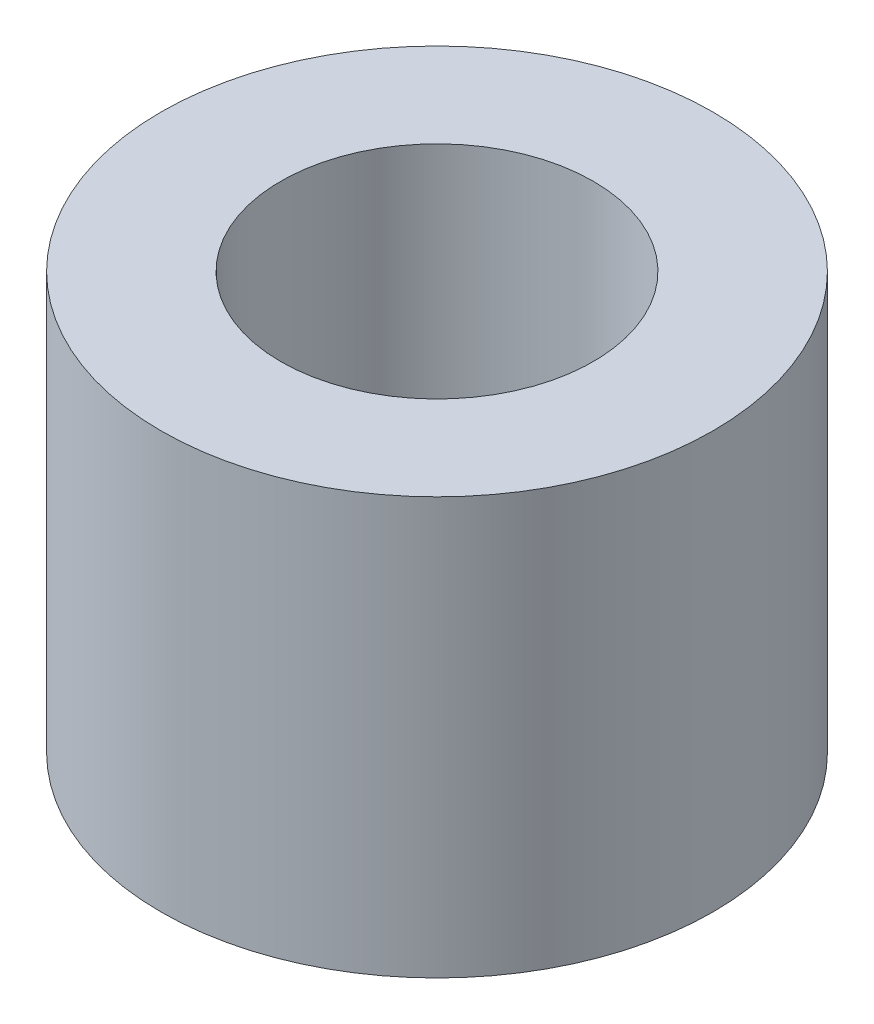
from build123d import *

# Parameters (mm, degrees)
SKETCH2_R            = 3.9751
BOSS_EXTRUDE1_DEPTH  = 3
M4_CLEARANCE_HOLE1_D = 4.5


with BuildPart() as part:
    # Sketch2 → Boss-Extrude1 (new body, symmetric)
    with BuildSketch(Plane(origin=(0, 0, 0), x_dir=(1, 0, 0), z_dir=(0, 1, 0))):
        Circle(SKETCH2_R)
    extrude(amount=BOSS_EXTRUDE1_DEPTH, both=True)

    # M4 Clearance Hole1 (through all)
    with Locations(Plane(origin=(0, 3, 0), x_dir=(1, 0, 0), z_dir=(0, 1, 0))):
        with Locations((0, 0)):
            Hole(M4_CLEARANCE_HOLE1_D / 2)


solid = part.part
